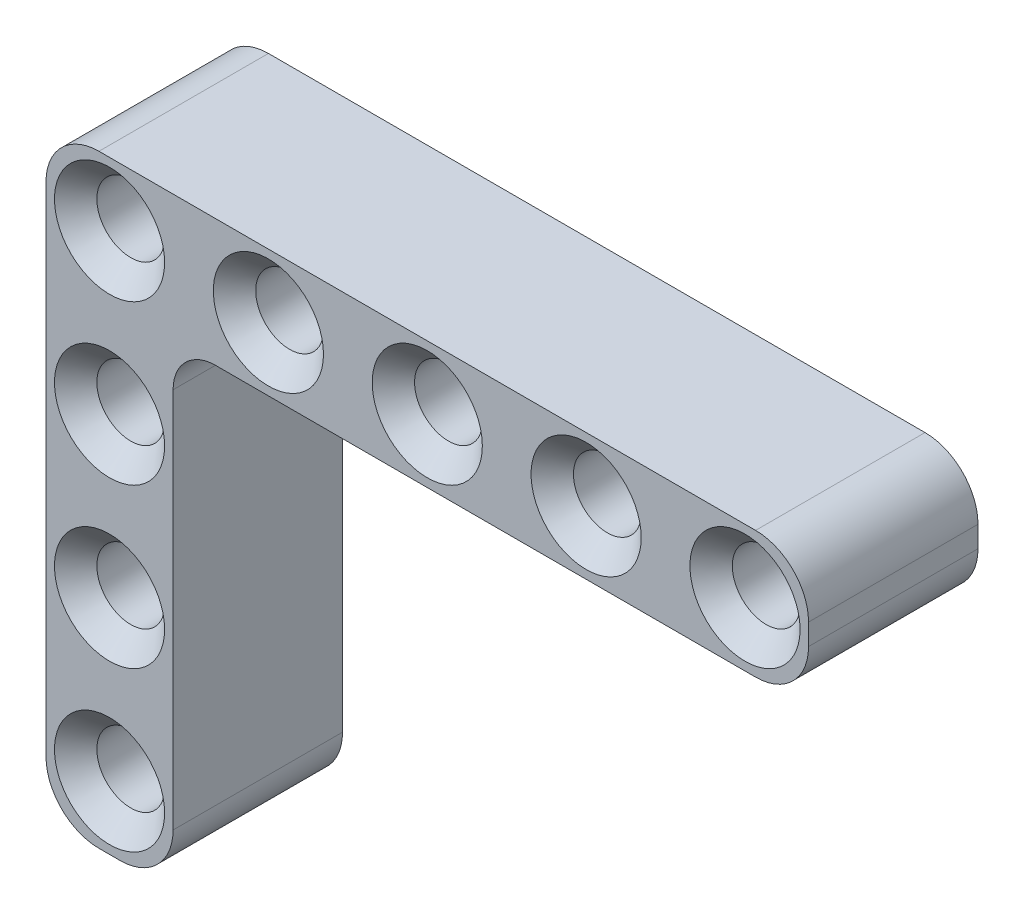
from build123d import *

# Parameters (mm, degrees)
SKETCH1_R           = 1.6
BOSS_EXTRUDE1_DEPTH = 8
CHAMFER1_SIZE       = 1
SKETCH2_R           = 1.6
BOSS_EXTRUDE3_DEPTH = 8
FILLET1_R           = 2
CHAMFER5_SIZE       = 1


with BuildPart() as part:
    # Sketch1 → Boss-Extrude1 (new body)
    with BuildSketch(Plane.XY):
        with BuildLine():
            Line((-0.5, 3), (30.5, 3))
            ThreePointArc((30.5, 3), (32.267766953, 2.267766953), (33, 0.5))
            Line((33, 0.5), (33, -0.5))
            ThreePointArc((33, -0.5), (32.267766953, -2.267766953), (30.5, -3))
            Line((30.5, -3), (-0.5, -3))
            ThreePointArc((-0.5, -3), (-2.267766953, -2.267766953), (-3, -0.5))
            Line((-3, -0.5), (-3, 0.5))
            ThreePointArc((-3, 0.5), (-2.267766953, 2.267766953), (-0.5, 3))
        make_face()
        Circle(SKETCH1_R, mode=Mode.SUBTRACT)
        with Locations((7.5, 0)):
            Circle(SKETCH1_R, mode=Mode.SUBTRACT)
        with Locations((15, 0)):
            Circle(SKETCH1_R, mode=Mode.SUBTRACT)
        with Locations((22.5, 0)):
            Circle(SKETCH1_R, mode=Mode.SUBTRACT)
        with Locations((30, 0)):
            Circle(SKETCH1_R, mode=Mode.SUBTRACT)
    extrude(amount=BOSS_EXTRUDE1_DEPTH)

    # Chamfer1
    chamfer1_edges = [part.edges().sort_by_distance(p)[0] for p in [
        (-1.6, 0, 0),
        (-1.6, 0, 8),
        (5.9, 0, 0),
        (5.9, 0, 8),
        (13.4, 0, 0),
        (13.4, 0, 8),
        (20.9, 0, 0),
        (20.9, 0, 8),
        (28.4, 0, 0),
        (28.4, 0, 8),
    ]]
    chamfer(chamfer1_edges, length=CHAMFER1_SIZE)

    # Sketch2 → Boss-Extrude3 (add)
    with BuildSketch(Plane.XY.offset(8)):
        with BuildLine():
            ThreePointArc((-0.5, -3), (-2.267766953, -2.267766953), (-3, -0.5))
            Line((-3, -0.5), (-3, -23))
            ThreePointArc((-3, -23), (-2.267766953, -24.767766953), (-0.5, -25.5))
            Line((-0.5, -25.5), (0.5, -25.5))
            ThreePointArc((0.5, -25.5), (2.267766953, -24.767766953), (3, -23))
            Line((3, -23), (3, -3))
            Line((3, -3), (-0.5, -3))
        make_face()
        with Locations((0, -22.5)):
            Circle(SKETCH2_R, mode=Mode.SUBTRACT)
        with Locations((0, -15)):
            Circle(SKETCH2_R, mode=Mode.SUBTRACT)
        with Locations((0, -7.5)):
            Circle(SKETCH2_R, mode=Mode.SUBTRACT)
    extrude(amount=-BOSS_EXTRUDE3_DEPTH)

    # Fillet1
    fillet1_edges = [part.edges().sort_by_distance(p)[0] for p in [
        (3, -3, 4),
    ]]
    fillet(fillet1_edges, radius=FILLET1_R)

    # Chamfer5
    chamfer5_edges = [part.edges().sort_by_distance(p)[0] for p in [
        (-1.6, -7.5, 8),
        (-1.6, -15, 8),
        (-1.6, -22.5, 8),
        (-1.6, -22.5, 0),
        (-1.6, -15, 0),
        (-1.6, -7.5, 0),
    ]]
    chamfer(chamfer5_edges, length=CHAMFER5_SIZE)


solid = part.part
